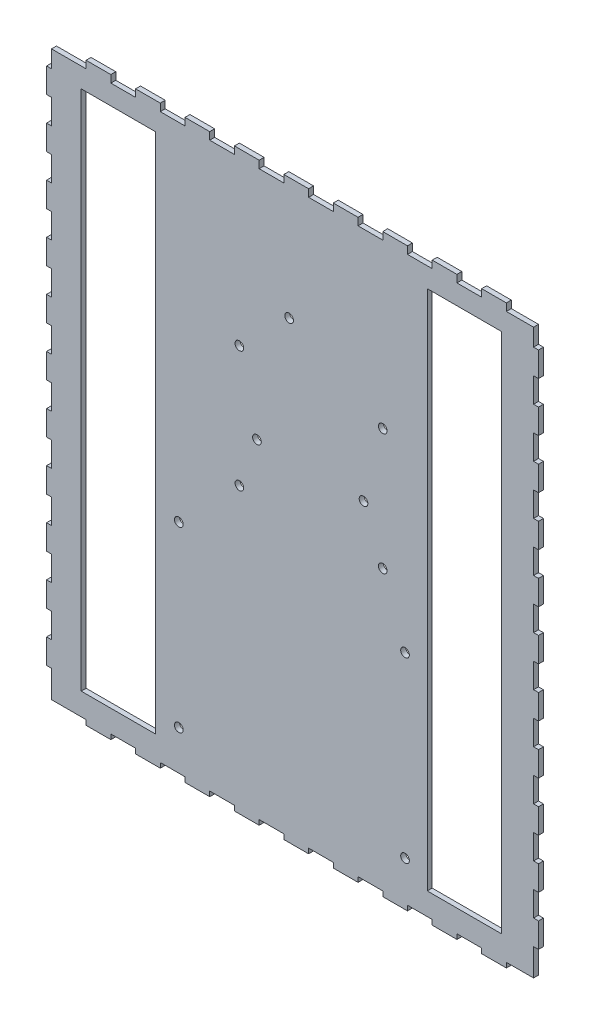
from build123d import *

# Parameters (mm, degrees)
SKETCH1_W               = 194
SKETCH1_H               = 227
BOSS_EXTRUDE1_DEPTH     = 2
SKETCH2_W               = 2
SKETCH2_H               = 10
BOSS_EXTRUDE2_DEPTH     = 3
LPATTERN1_COUNT         = 11
LPATTERN1_PITCH         = 20
SKETCH4_W               = 2
SKETCH4_H               = 10
BOSS_EXTRUDE3_DEPTH     = 3
LPATTERN2_COUNT         = 11
LPATTERN2_PITCH         = 20
SKETCH5_W               = 10
SKETCH5_H               = 2
BOSS_EXTRUDE4_DEPTH     = 3
LPATTERN3_COUNT         = 9
LPATTERN3_PITCH         = 20
SKETCH6_W               = 10
SKETCH6_H               = 2
BOSS_EXTRUDE5_DEPTH     = 3
LPATTERN4_COUNT         = 9
LPATTERN4_PITCH         = 20
SKETCH7_W               = 30
SKETCH7_H               = 211
CUT_EXTRUDE1_DEPTH      = 3
SKETCH8_R               = 1.75
SKETCH8_W               = 30
SKETCH8_H               = 211
CUT_EXTRUDE2_DEPTH      = 3
ENL_V_START             = -2
ESQUISSE1_W             = 1
ESQUISSE1_H             = 231.630862985
ENL_V_MAT_EXTRU_1_DEPTH = 2
ESQUISSE2_W             = 1
ESQUISSE2_H             = 7
ESQUISSE2_H_2           = 10
ESQUISSE2_W_2           = 10
ESQUISSE2_H_3           = 1
ESQUISSE2_W_3           = 14
BOSS_EXTRU_1_DEPTH      = 2
ESQUISSE3_R             = 1.75
ENL_V_MAT_EXTRU_2_DEPTH = 3


with BuildPart() as part:
    # Sketch1 → Boss-Extrude1 (new body)
    with BuildSketch(Plane.XY):
        with Locations((97, 113.5)):
            Rectangle(SKETCH1_W, SKETCH1_H)
    extrude(amount=BOSS_EXTRUDE1_DEPTH)

    # Sketch2 → Boss-Extrude2 (add)
    with BuildSketch(Plane(origin=(194, 0, 0), x_dir=(0, 0, -1), z_dir=(1, 0, 0))):
        with Locations((-1, 15)):
            Rectangle(SKETCH2_W, SKETCH2_H)
    boss_extrude2 = extrude(amount=BOSS_EXTRUDE2_DEPTH)

    # LPattern1: Boss-Extrude2 ×11
    with Locations(*[(0, i * LPATTERN1_PITCH, 0) for i in range(1, LPATTERN1_COUNT)]):
        add(boss_extrude2)

    # Sketch4 → Boss-Extrude3 (add)
    with BuildSketch(Plane.ZY):
        with Locations((1, 15)):
            Rectangle(SKETCH4_W, SKETCH4_H)
    boss_extrude3 = extrude(amount=BOSS_EXTRUDE3_DEPTH)

    # LPattern2: Boss-Extrude3 ×11
    with Locations(*[(0, i * LPATTERN2_PITCH, 0) for i in range(1, LPATTERN2_COUNT)]):
        add(boss_extrude3)

    # Sketch5 → Boss-Extrude4 (add)
    with BuildSketch(Plane.XZ):
        with Locations((179, 1)):
            Rectangle(SKETCH5_W, SKETCH5_H)
    boss_extrude4 = extrude(amount=BOSS_EXTRUDE4_DEPTH)

    # LPattern3: Boss-Extrude4 ×9
    with Locations(*[(-i * LPATTERN3_PITCH, 0, 0) for i in range(1, LPATTERN3_COUNT)]):
        add(boss_extrude4)

    # Sketch6 → Boss-Extrude5 (add)
    with BuildSketch(Plane(origin=(0, 227, 0), x_dir=(1, 0, 0), z_dir=(0, 1, 0))):
        with Locations((179, -1)):
            Rectangle(SKETCH6_W, SKETCH6_H)
    boss_extrude5 = extrude(amount=BOSS_EXTRUDE5_DEPTH)

    # LPattern4: Boss-Extrude5 ×9
    with Locations(*[(-i * LPATTERN4_PITCH, 0, 0) for i in range(1, LPATTERN4_COUNT)]):
        add(boss_extrude5)

    # Sketch7 → Cut-Extrude1 (cut, through all)
    with BuildSketch(Plane.XY.offset(2)):
        with Locations((27, 113.5)):
            Rectangle(SKETCH7_W, SKETCH7_H)
    extrude(amount=-CUT_EXTRUDE1_DEPTH, mode=Mode.SUBTRACT)

    # Sketch8 → Cut-Extrude2 (cut, through all)
    with BuildSketch(Plane.XY.offset(2)):
        with Locations((143, 15)):
            Circle(SKETCH8_R)
        with Locations((51.5, 15)):
            Circle(SKETCH8_R)
        with Locations((143, 87)):
            Circle(SKETCH8_R)
        with Locations((51.5, 87)):
            Circle(SKETCH8_R)
        with Locations((134, 112)):
            Circle(SKETCH8_R)
        with Locations((76, 112)):
            Circle(SKETCH8_R)
        with Locations((134, 161)):
            Circle(SKETCH8_R)
        with Locations((76, 161)):
            Circle(SKETCH8_R)
        with Locations((167, 113.5)):
            Rectangle(SKETCH8_W, SKETCH8_H)
    extrude(amount=-CUT_EXTRUDE2_DEPTH, mode=Mode.SUBTRACT)

    # Esquisse1 → Enlèv. mat.-Extru.1 (cut)
    with BuildSketch(Plane(origin=(0, 0, 0), x_dir=(-1, 0, 0), z_dir=(0, 0, -1)).offset(ENL_V_START)):
        with Locations((2.5, 104.184568508)):
            Rectangle(ESQUISSE1_W, ESQUISSE1_H)
    extrude(amount=ENL_V_MAT_EXTRU_1_DEPTH, mode=Mode.SUBTRACT)

    # Esquisse2 → Boss.-Extru.1 (add)
    with BuildSketch(Plane(origin=(0, 0, 0), x_dir=(-1, 0, 0), z_dir=(0, 0, -1))):
        with Locations((-194.5, 223.5)):
            Rectangle(ESQUISSE2_W, ESQUISSE2_H)
        with Locations((-194.5, 205)):
            Rectangle(ESQUISSE2_W, ESQUISSE2_H_2)
        with Locations((-194.5, 185)):
            Rectangle(ESQUISSE2_W, ESQUISSE2_H_2)
        with Locations((-194.5, 165)):
            Rectangle(ESQUISSE2_W, ESQUISSE2_H_2)
        with Locations((-194.5, 145)):
            Rectangle(ESQUISSE2_W, ESQUISSE2_H_2)
        with Locations((-194.5, 125)):
            Rectangle(ESQUISSE2_W, ESQUISSE2_H_2)
        with Locations((-194.5, 105)):
            Rectangle(ESQUISSE2_W, ESQUISSE2_H_2)
        with Locations((-194.5, 85)):
            Rectangle(ESQUISSE2_W, ESQUISSE2_H_2)
        with Locations((-194.5, 65)):
            Rectangle(ESQUISSE2_W, ESQUISSE2_H_2)
        with Locations((-194.5, 45)):
            Rectangle(ESQUISSE2_W, ESQUISSE2_H_2)
        with Locations((-194.5, 25)):
            Rectangle(ESQUISSE2_W, ESQUISSE2_H_2)
        Polygon((-194, 0), (-194, 10), (-195, 10), (-195, -1), (-184, -1), (-184, 0), align=None)
        with Locations((-169, -0.5)):
            Rectangle(ESQUISSE2_W_2, ESQUISSE2_H_3)
        with Locations((-149, -0.5)):
            Rectangle(ESQUISSE2_W_2, ESQUISSE2_H_3)
        with Locations((-129, -0.5)):
            Rectangle(ESQUISSE2_W_2, ESQUISSE2_H_3)
        with Locations((-109, -0.5)):
            Rectangle(ESQUISSE2_W_2, ESQUISSE2_H_3)
        with Locations((-89, -0.5)):
            Rectangle(ESQUISSE2_W_2, ESQUISSE2_H_3)
        with Locations((-69, -0.5)):
            Rectangle(ESQUISSE2_W_2, ESQUISSE2_H_3)
        with Locations((-49, -0.5)):
            Rectangle(ESQUISSE2_W_2, ESQUISSE2_H_3)
        with Locations((-29, -0.5)):
            Rectangle(ESQUISSE2_W_2, ESQUISSE2_H_3)
        with Locations((-7, -0.5)):
            Rectangle(ESQUISSE2_W_3, ESQUISSE2_H_3)
    extrude(amount=-BOSS_EXTRU_1_DEPTH)

    # Esquisse3 → Enlèv. mat.-Extru.2 (cut, through all)
    with BuildSketch(Plane(origin=(0, 0, 0), x_dir=(-1, 0, 0), z_dir=(0, 0, -1))):
        with Locations((-96.112690171, 180.774445285)):
            Circle(ESQUISSE3_R)
        with Locations((-126.212690171, 131.674445285)):
            Circle(ESQUISSE3_R)
        with Locations((-83.112690171, 131.674445285)):
            Circle(ESQUISSE3_R)
    extrude(amount=-ENL_V_MAT_EXTRU_2_DEPTH, mode=Mode.SUBTRACT)


solid = part.part
